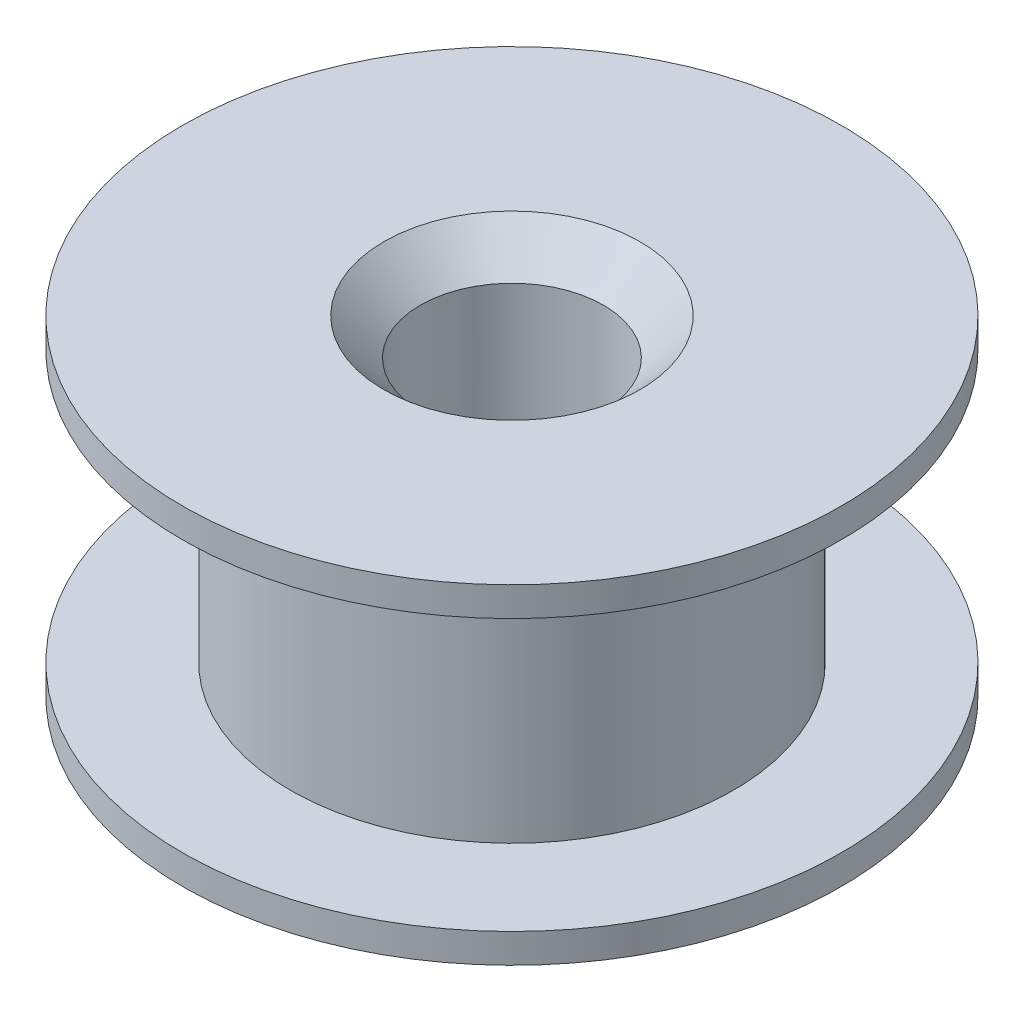
from build123d import *

# Parameters (mm, degrees)
CHAMFER_1_SIZE = 1
CHAMFER_2_SIZE = 1


with BuildPart() as part:
    # Эскиз1 → Повернуть1 (revolve)
    with BuildSketch(Plane.XY):
        Polygon((-2.5, 0), (-9, 0), (-9, 0.8), (-6.05, 0.8), (-6.05, 8.2), (-9, 8.2), (-9, 9), (-2.5, 9), align=None)
    revolve(axis=Axis((0, 9, 0), (0, -1, 0)))

    # Фаска1
    chamfer_1_edges = [part.edges().sort_by_distance(p)[0] for p in [
        (2.5, 9, 0),
    ]]
    chamfer(chamfer_1_edges, length=CHAMFER_1_SIZE)

    # Фаска2
    chamfer_2_edges = [part.edges().sort_by_distance(p)[0] for p in [
        (2.5, 0, 0),
    ]]
    chamfer(chamfer_2_edges, length=CHAMFER_2_SIZE)


solid = part.part
